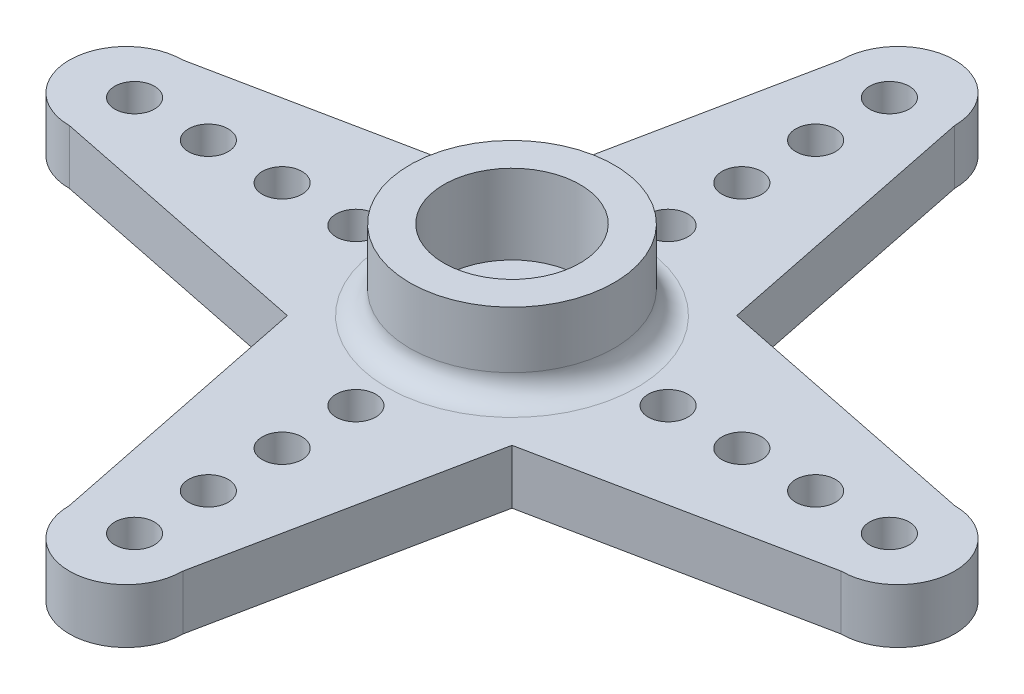
from build123d import *

# Parameters (mm, degrees)
SKETCH1_R           = 1.5
BOSS_EXTRUDE1_DEPTH = 2.4
SKETCH2_R           = 4.5
SKETCH2_R_2         = 3
BOSS_EXTRUDE2_DEPTH = 3.5
FILLET1_R           = 1
SKETCH3_R           = 0.875
CUT_EXTRUDE1_DEPTH  = 3.5
SKETCH4_R           = 4.375
CUT_EXTRUDE2_DEPTH  = 0.5


with BuildPart() as part:
    # Sketch1 → Boss-Extrude1 (new body)
    with BuildSketch(Plane(origin=(0, 0, 0), x_dir=(1, 0, 0), z_dir=(0, 1, 0))):
        with BuildLine():
            Line((-16.999165859, 2.5), (-4.949747468, 4.949747468))
            Line((-4.949747468, 4.949747468), (-2.5, 17.001645777))
            ThreePointArc((-2.5, 17.001645777), (0, 19.501645777), (2.5, 17.001645777))
            Line((2.5, 17.001645777), (4.949747468, 4.949747468))
            Line((4.949747468, 4.949747468), (17.000896169, 2.5))
            ThreePointArc((17.000896169, 2.5), (19.500896169, 0), (17.000896169, -2.5))
            Line((17.000896169, -2.5), (4.949747468, -4.949747468))
            Line((4.949747468, -4.949747468), (2.5, -16.999958072))
            ThreePointArc((2.5, -16.999958072), (0, -19.499958072), (-2.5, -16.999958072))
            Line((-2.5, -16.999958072), (-4.949747468, -4.949747468))
            Line((-4.949747468, -4.949747468), (-16.999165859, -2.5))
            ThreePointArc((-16.999165859, -2.5), (-19.499165859, 0), (-16.999165859, 2.5))
        make_face()
        Circle(SKETCH1_R, mode=Mode.SUBTRACT)
    extrude(amount=BOSS_EXTRUDE1_DEPTH)

    # Sketch2 → Boss-Extrude2 (add)
    with BuildSketch(Plane(origin=(0, 2.4, 0), x_dir=(1, 0, 0), z_dir=(0, 1, 0))):
        Circle(SKETCH2_R)
        Circle(SKETCH2_R_2, mode=Mode.SUBTRACT)
    extrude(amount=BOSS_EXTRUDE2_DEPTH)

    # Fillet1
    fillet1_edges = [part.edges().sort_by_distance(p)[0] for p in [
        (-4.5, 2.4, 0),
    ]]
    fillet(fillet1_edges, radius=FILLET1_R)

    # Sketch3 → Cut-Extrude1 (cut)
    with BuildSketch(Plane(origin=(0, 2.4, 0), x_dir=(1, 0, 0), z_dir=(0, 1, 0))):
        with Locations((0, -16.626645777)):
            Circle(SKETCH3_R)
        with Locations((0, -13.376645777)):
            Circle(SKETCH3_R)
        with Locations((0, -10.126645777)):
            Circle(SKETCH3_R)
        with Locations((0, -6.876645777)):
            Circle(SKETCH3_R)
        with Locations((-6.876645777, 0)):
            Circle(SKETCH3_R)
        with Locations((-10.126645777, 0)):
            Circle(SKETCH3_R)
        with Locations((-13.376645777, 0)):
            Circle(SKETCH3_R)
        with Locations((-16.626645777, 0)):
            Circle(SKETCH3_R)
        with Locations((0, 6.876645777)):
            Circle(SKETCH3_R)
        with BuildLine():
            ThreePointArc((0.875, 10.126645777), (0.618718434, 10.745364211), (0, 11.001645777))
            Line((0, 11.001645777), (0, 9.251645777))
            ThreePointArc((0, 9.251645777), (0.618718434, 9.507927344), (0.875, 10.126645777))
        make_face()
        with BuildLine():
            Line((0, 9.251645777), (0, 11.001645777))
            ThreePointArc((0, 11.001645777), (-0.875, 10.126645777), (0, 9.251645777))
        make_face()
        with BuildLine():
            ThreePointArc((0.875, 13.376645777), (0.618718434, 13.995364211), (0, 14.251645777))
            Line((0, 14.251645777), (0, 12.501645777))
            ThreePointArc((0, 12.501645777), (0.618718434, 12.757927344), (0.875, 13.376645777))
        make_face()
        with BuildLine():
            Line((0, 12.501645777), (0, 14.251645777))
            ThreePointArc((0, 14.251645777), (-0.875, 13.376645777), (0, 12.501645777))
        make_face()
        with BuildLine():
            ThreePointArc((0, 17.501645777), (-0.875, 16.626645777), (0, 15.751645777))
            Line((0, 15.751645777), (0, 17.501645777))
        make_face()
        with BuildLine():
            Line((0, 17.501645777), (0, 15.751645777))
            ThreePointArc((0, 15.751645777), (0.618718434, 16.007927344), (0.875, 16.626645777))
            ThreePointArc((0.875, 16.626645777), (0.618718434, 17.245364211), (0, 17.501645777))
        make_face()
        with Locations((6.876645777, 0)):
            Circle(SKETCH3_R)
        with Locations((13.376645777, 0)):
            Circle(SKETCH3_R)
        with Locations((16.626645777, 0)):
            Circle(SKETCH3_R)
        with Locations((10.126645777, 0)):
            Circle(SKETCH3_R)
    extrude(amount=-CUT_EXTRUDE1_DEPTH, mode=Mode.SUBTRACT)

    # Sketch4 → Cut-Extrude2 (cut)
    with BuildSketch(Plane.XZ):
        Circle(SKETCH4_R)
    extrude(amount=-CUT_EXTRUDE2_DEPTH, mode=Mode.SUBTRACT)


solid = part.part
